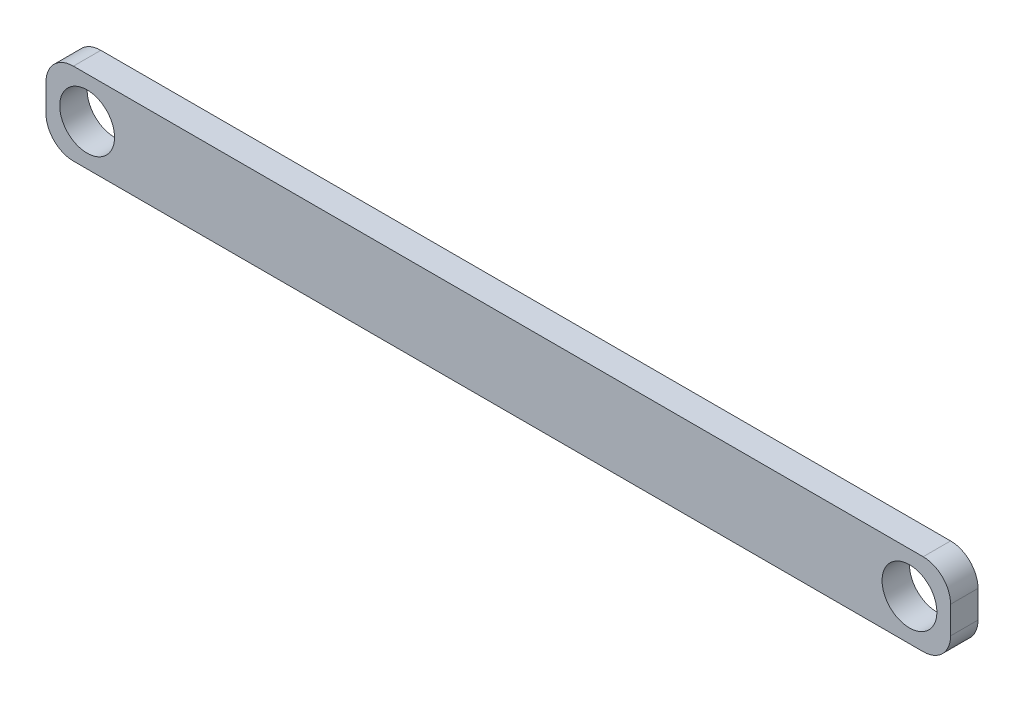
from build123d import *

# Parameters (mm, degrees)
CROQUIS1_R              = 10
SALIENTE_EXTRUIR1_DEPTH = 5


with BuildPart() as part:
    # Croquis1 → Saliente-Extruir1 (new body, symmetric)
    with BuildSketch(Plane.XY):
        with BuildLine():
            Line((-155, 15), (155, 15))
            ThreePointArc((155, 15), (162.071067812, 12.071067812), (165, 5))
            Line((165, 5), (165, -5))
            ThreePointArc((165, -5), (162.071067812, -12.071067812), (155, -15))
            Line((155, -15), (-155, -15))
            ThreePointArc((-155, -15), (-162.071067812, -12.071067812), (-165, -5))
            Line((-165, -5), (-165, 5))
            ThreePointArc((-165, 5), (-162.071067812, 12.071067812), (-155, 15))
        make_face()
        with Locations((-150, 0)):
            Circle(CROQUIS1_R, mode=Mode.SUBTRACT)
        with Locations((150, 0)):
            Circle(CROQUIS1_R, mode=Mode.SUBTRACT)
    extrude(amount=SALIENTE_EXTRUIR1_DEPTH, both=True)


solid = part.part
